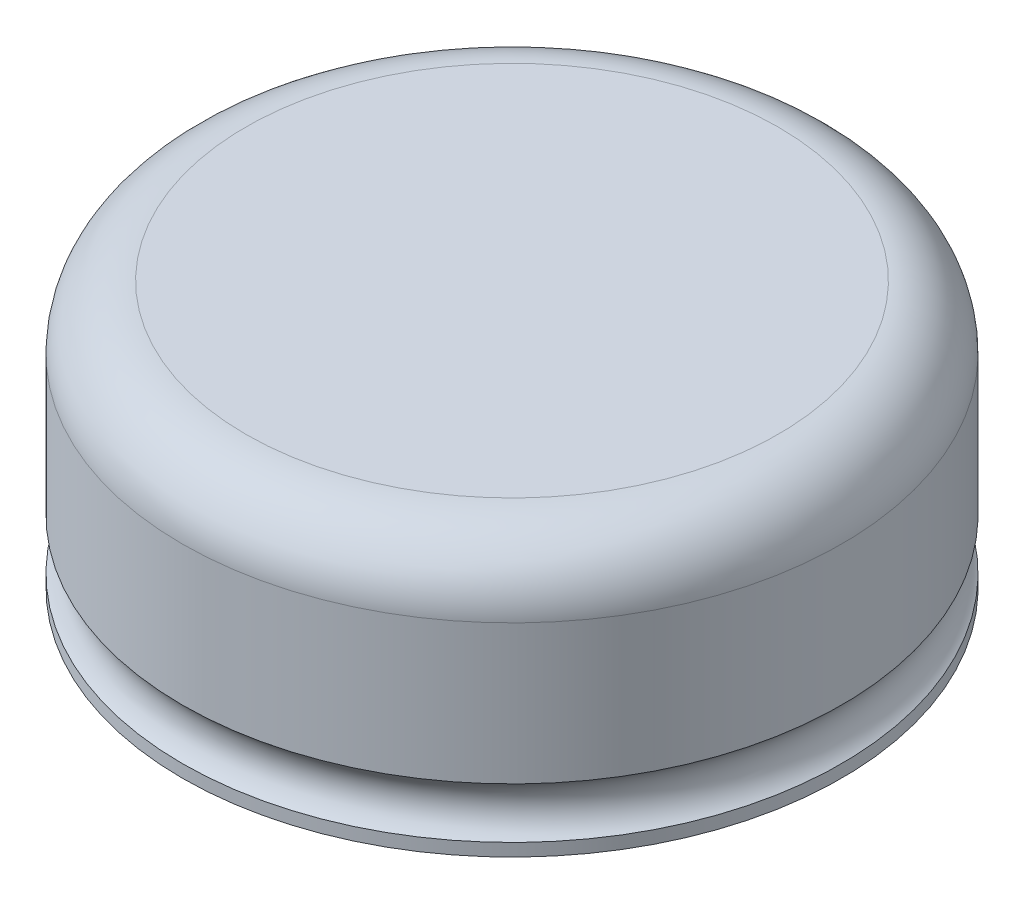
from build123d import *

# Parameters (mm, degrees)
SKETCH_2_R      = 26
EXTRUDE_1_DEPTH = 15
FILLET_1_R      = 5


with BuildPart() as part:
    # 草图1 → 旋转1 (revolve)
    with BuildSketch(Plane.XY):
        with BuildLine():
            Line((0, 0), (26, 0))
            Line((26, 0), (26, 1))
            ThreePointArc((26, 1), (25, 3), (26, 5))
            Line((26, 5), (26, 6))
            Line((26, 6), (0, 6))
            Line((0, 6), (0, 0))
        make_face()
    revolve(axis=Axis((0, 0, 0), (0, -1, 0)))

    # 草图2 → 凸台-拉伸1 (add)
    with BuildSketch(Plane(origin=(0, 6, 0), x_dir=(1, 0, 0), z_dir=(0, 1, 0))):
        Circle(SKETCH_2_R)
    extrude(amount=EXTRUDE_1_DEPTH)

    # 圆角1
    fillet_1_edges = [part.edges().sort_by_distance(p)[0] for p in [
        (-26, 21, 0),
    ]]
    fillet(fillet_1_edges, radius=FILLET_1_R)


solid = part.part
